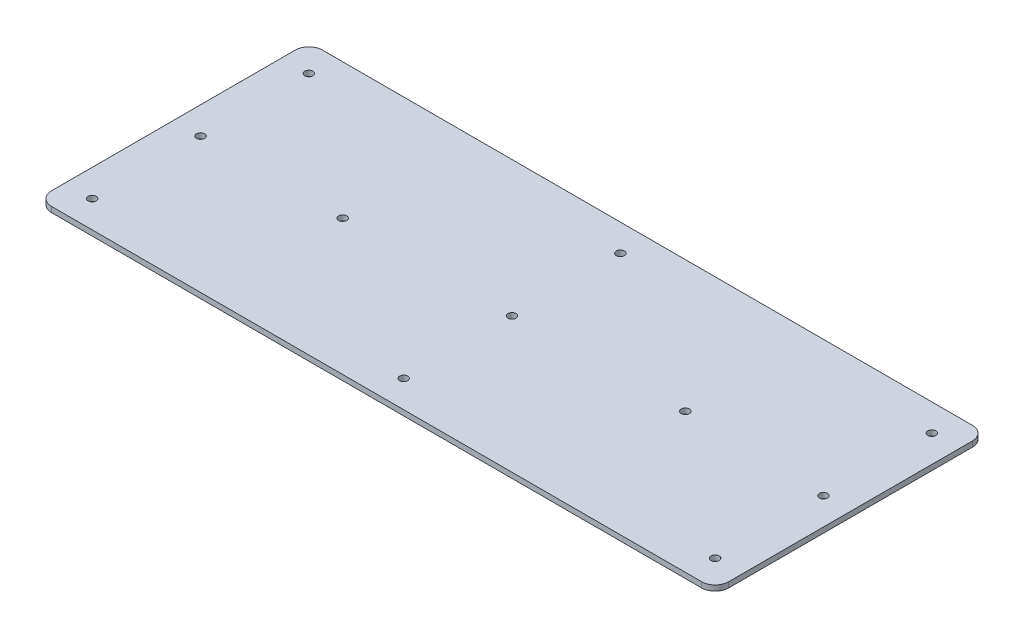
from build123d import *

# Parameters (mm, degrees)
SKETCH1_R           = 1.5
BOSS_EXTRUDE1_DEPTH = 2


with BuildPart() as part:
    # Sketch1 → Boss-Extrude1 (new body)
    with BuildSketch(Plane(origin=(0, 0, 0), x_dir=(1, 0, 0), z_dir=(0, 1, 0))):
        with BuildLine():
            Line((-120, 50), (120, 50))
            ThreePointArc((120, 50), (123.535533906, 48.535533906), (125, 45))
            Line((125, 45), (125, -45))
            ThreePointArc((125, -45), (123.535533906, -48.535533906), (120, -50))
            Line((120, -50), (-120, -50))
            ThreePointArc((-120, -50), (-123.535533906, -48.535533906), (-125, -45))
            Line((-125, -45), (-125, 45))
            ThreePointArc((-125, 45), (-123.535533906, 48.535533906), (-120, 50))
        make_face()
        with Locations((0, 40)):
            Circle(SKETCH1_R, mode=Mode.SUBTRACT)
        with Locations((-115, 40)):
            Circle(SKETCH1_R, mode=Mode.SUBTRACT)
        with Locations((115, 40)):
            Circle(SKETCH1_R, mode=Mode.SUBTRACT)
        with Locations((-115, 0)):
            Circle(SKETCH1_R, mode=Mode.SUBTRACT)
        with Locations((-115, -40)):
            Circle(SKETCH1_R, mode=Mode.SUBTRACT)
        with Locations((0, -40)):
            Circle(SKETCH1_R, mode=Mode.SUBTRACT)
        with Locations((115, -40)):
            Circle(SKETCH1_R, mode=Mode.SUBTRACT)
        Circle(SKETCH1_R, mode=Mode.SUBTRACT)
        with Locations((115, 0)):
            Circle(SKETCH1_R, mode=Mode.SUBTRACT)
        with Locations((-62.5, 0)):
            Circle(SKETCH1_R, mode=Mode.SUBTRACT)
        with Locations((62.5, 1.5)):
            Circle(SKETCH1_R, mode=Mode.SUBTRACT)
    extrude(amount=BOSS_EXTRUDE1_DEPTH)


solid = part.part
